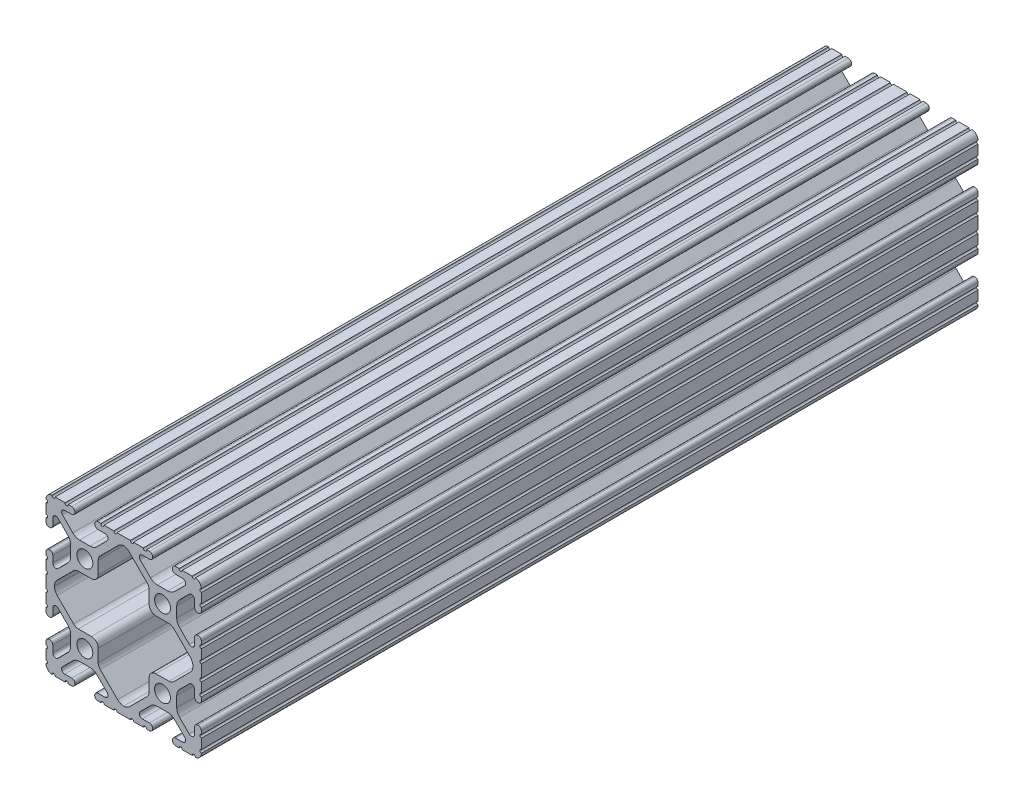
from build123d import *

# Parameters (mm, degrees)
SKETCH1_R      = 2.6035
EXTRUDE1_DEPTH = 254


with BuildPart() as part:
    # Sketch1 → Extrude1 (new body)
    with BuildSketch(Plane.XY):
        with BuildLine():
            Line((-2.210122516, -25.4), (2.210122516, -25.4))
            ThreePointArc((2.210122516, -25.4), (2.712319242, -24.815433371), (3.214515968, -25.4))
            Line((3.214515968, -25.4), (6.453532688, -25.4))
            ThreePointArc((6.453532688, -25.4), (6.955729414, -24.815433371), (7.45792614, -25.4))
            Line((7.45792614, -25.4), (8.405130016, -25.4))
            ThreePointArc((8.405130016, -25.4), (9.151169169, -25.100362415), (9.461500022, -24.358707602))
            Line((9.461500022, -24.358707602), (9.4615, -24.231492399))
            ThreePointArc((9.4615, -24.231492399), (9.151169155, -23.489837593), (8.405130016, -23.1902))
            Line((8.405130016, -23.1902), (6.087754002, -23.1902))
            ThreePointArc((6.087754002, -23.1902), (5.173448619, -22.579280675), (5.387974958, -21.500783941))
            Line((5.387974958, -21.500783941), (8.763022929, -18.12573597))
            ThreePointArc((8.763022929, -18.12573597), (9.793067061, -17.437482484), (11.008086959, -17.1958))
            Line((11.008086959, -17.1958), (14.391913041, -17.1958))
            ThreePointArc((14.391913041, -17.1958), (15.606932939, -17.437482484), (16.636977071, -18.12573597))
            Line((16.636977071, -18.12573597), (20.012025042, -21.500783941))
            ThreePointArc((20.012025042, -21.500783941), (20.223734168, -22.586011733), (19.297652818, -23.190092399))
            Line((19.297652818, -23.190092399), (16.9799, -23.190092399))
            ThreePointArc((16.9799, -23.190092399), (16.243518998, -23.495111397), (15.9385, -24.231492399))
            Line((15.9385, -24.231492399), (15.9385, -24.358492399))
            ThreePointArc((15.9385, -24.358492399), (16.248754204, -25.100286874), (16.994869984, -25.4))
            Line((16.994869984, -25.4), (18.134015685, -25.4))
            ThreePointArc((18.134015685, -25.4), (18.636212411, -24.815433371), (19.138409137, -25.4))
            Line((19.138409137, -25.4), (20.1295, -25.4))
            Line((20.1295, -25.4), (22.413213213, -25.4))
            ThreePointArc((22.413213213, -25.4), (22.915409939, -24.815433371), (23.417606664, -25.4))
            Line((23.417606664, -25.4), (23.450078724, -25.4))
            ThreePointArc((23.450078724, -25.4), (24.838729535, -24.730064765), (25.4, -23.294049529))
            Line((25.4, -23.294049529), (25.4, -23.268649529))
            ThreePointArc((25.4, -23.268649529), (24.892, -22.760649529), (25.4, -22.252649529))
            Line((25.4, -22.252649529), (25.4, -21.160449529))
            Line((25.4, -21.160449529), (25.4, -19.025239356))
            ThreePointArc((25.4, -19.025239356), (24.892, -18.517239356), (25.4, -18.009239356))
            Line((25.4, -18.009239356), (25.4, -16.91604181))
            ThreePointArc((25.4, -16.91604181), (25.094981002, -16.179660808), (24.3586, -15.87464181))
            Line((24.3586, -15.87464181), (24.2316, -15.87464181))
            ThreePointArc((24.2316, -15.87464181), (23.495218998, -16.179660808), (23.1902, -16.91604181))
            Line((23.1902, -16.91604181), (23.1902, -19.100988789))
            ThreePointArc((23.1902, -19.100988789), (22.563006367, -20.039650394), (21.45577951, -19.819409279))
            Line((21.45577951, -19.819409279), (18.27813597, -16.641765738))
            ThreePointArc((18.27813597, -16.641765738), (17.589882484, -15.611721606), (17.3482, -14.396701708))
            Line((17.3482, -14.396701708), (17.3482, -11.003495043))
            ThreePointArc((17.3482, -11.003495043), (17.590610762, -9.786718415), (18.280827, -8.755743204))
            Line((18.280827, -8.755743204), (21.45664064, -5.587529241))
            ThreePointArc((21.45664064, -5.587529241), (22.563568521, -5.368381274), (23.1902, -6.30680983))
            Line((23.1902, -6.30680983), (23.1902, -8.48395819))
            ThreePointArc((23.1902, -8.48395819), (23.495218998, -9.220339192), (24.2316, -9.52535819))
            Line((24.2316, -9.52535819), (24.3586, -9.52535819))
            ThreePointArc((24.3586, -9.52535819), (25.094981002, -9.220339192), (25.4, -8.48395819))
            Line((25.4, -8.48395819), (25.4, -7.327686685))
            ThreePointArc((25.4, -7.327686685), (24.892, -6.819686685), (25.4, -6.311686685))
            Line((25.4, -6.311686685), (25.4, -3.084276513))
            ThreePointArc((25.4, -3.084276513), (24.892, -2.576276513), (25.4, -2.068276513))
            Line((25.4, -2.068276513), (25.4, 2.068276513))
            ThreePointArc((25.4, 2.068276513), (24.892, 2.576276513), (25.4, 3.084276513))
            Line((25.4, 3.084276513), (25.4, 6.311686685))
            ThreePointArc((25.4, 6.311686685), (24.892, 6.819686685), (25.4, 7.327686685))
            Line((25.4, 7.327686685), (25.4, 8.48395819))
            ThreePointArc((25.4, 8.48395819), (25.094981002, 9.220339192), (24.3586, 9.52535819))
            Line((24.3586, 9.52535819), (24.2316, 9.52535819))
            ThreePointArc((24.2316, 9.52535819), (23.495218998, 9.220339192), (23.1902, 8.48395819))
            Line((23.1902, 8.48395819), (23.1902, 6.30680983))
            ThreePointArc((23.1902, 6.30680983), (22.563568521, 5.368381274), (21.45664064, 5.587529241))
            Line((21.45664064, 5.587529241), (18.280827, 8.755743204))
            ThreePointArc((18.280827, 8.755743204), (17.590610762, 9.786718415), (17.3482, 11.003495043))
            Line((17.3482, 11.003495043), (17.3482, 14.396701708))
            ThreePointArc((17.3482, 14.396701708), (17.589882484, 15.611721606), (18.27813597, 16.641765738))
            Line((18.27813597, 16.641765738), (21.45577951, 19.819409279))
            ThreePointArc((21.45577951, 19.819409279), (22.563006367, 20.039650394), (23.1902, 19.100988789))
            Line((23.1902, 19.100988789), (23.1902, 16.91604181))
            ThreePointArc((23.1902, 16.91604181), (23.495218998, 16.179660808), (24.2316, 15.87464181))
            Line((24.2316, 15.87464181), (24.3586, 15.87464181))
            ThreePointArc((24.3586, 15.87464181), (25.094981002, 16.179660808), (25.4, 16.91604181))
            Line((25.4, 16.91604181), (25.4, 18.009239356))
            ThreePointArc((25.4, 18.009239356), (24.892, 18.517239356), (25.4, 19.025239356))
            Line((25.4, 19.025239356), (25.4, 21.160449529))
            Line((25.4, 21.160449529), (25.4, 22.252649529))
            ThreePointArc((25.4, 22.252649529), (24.892, 22.760649529), (25.4, 23.268649529))
            Line((25.4, 23.268649529), (25.4, 23.294049529))
            ThreePointArc((25.4, 23.294049529), (24.838729535, 24.730064765), (23.450078724, 25.4))
            Line((23.450078724, 25.4), (23.417606664, 25.4))
            ThreePointArc((23.417606664, 25.4), (22.915409939, 24.815433371), (22.413213213, 25.4))
            Line((22.413213213, 25.4), (20.1295, 25.4))
            Line((20.1295, 25.4), (19.138409137, 25.4))
            ThreePointArc((19.138409137, 25.4), (18.636212411, 24.815433371), (18.134015685, 25.4))
            Line((18.134015685, 25.4), (16.994869984, 25.4))
            ThreePointArc((16.994869984, 25.4), (16.248754204, 25.100286874), (15.9385, 24.358492399))
            Line((15.9385, 24.358492399), (15.9385, 24.231492399))
            ThreePointArc((15.9385, 24.231492399), (16.243518998, 23.495111397), (16.9799, 23.190092399))
            Line((16.9799, 23.190092399), (19.297652818, 23.190092399))
            ThreePointArc((19.297652818, 23.190092399), (20.223734168, 22.586011733), (20.012025042, 21.500783941))
            Line((20.012025042, 21.500783941), (16.636977071, 18.12573597))
            ThreePointArc((16.636977071, 18.12573597), (15.606932939, 17.437482484), (14.391913041, 17.1958))
            Line((14.391913041, 17.1958), (11.008086959, 17.1958))
            ThreePointArc((11.008086959, 17.1958), (9.793067061, 17.437482484), (8.763022929, 18.12573597))
            Line((8.763022929, 18.12573597), (5.387974958, 21.500783941))
            ThreePointArc((5.387974958, 21.500783941), (5.173448619, 22.579280675), (6.087754002, 23.1902))
            Line((6.087754002, 23.1902), (8.405130016, 23.1902))
            ThreePointArc((8.405130016, 23.1902), (9.151169155, 23.489837593), (9.4615, 24.231492399))
            Line((9.4615, 24.231492399), (9.461500022, 24.358707602))
            ThreePointArc((9.461500022, 24.358707602), (9.151169169, 25.100362415), (8.405130016, 25.4))
            Line((8.405130016, 25.4), (7.45792614, 25.4))
            ThreePointArc((7.45792614, 25.4), (6.955729414, 24.815433371), (6.453532688, 25.4))
            Line((6.453532688, 25.4), (3.214515968, 25.4))
            ThreePointArc((3.214515968, 25.4), (2.712319242, 24.815433371), (2.210122516, 25.4))
            Line((2.210122516, 25.4), (-2.210122516, 25.4))
            ThreePointArc((-2.210122516, 25.4), (-2.712319242, 24.815433371), (-3.214515968, 25.4))
            Line((-3.214515968, 25.4), (-5.2705, 25.4))
            Line((-5.2705, 25.4), (-6.453532688, 25.4))
            ThreePointArc((-6.453532688, 25.4), (-6.955729414, 24.815433371), (-7.45792614, 25.4))
            Line((-7.45792614, 25.4), (-8.405130016, 25.4))
            ThreePointArc((-8.405130016, 25.4), (-9.151169169, 25.100362415), (-9.461500022, 24.358707602))
            Line((-9.461500022, 24.358707602), (-9.4615, 24.231492399))
            ThreePointArc((-9.4615, 24.231492399), (-9.151169155, 23.489837593), (-8.405130016, 23.1902))
            Line((-8.405130016, 23.1902), (-6.087754002, 23.1902))
            ThreePointArc((-6.087754002, 23.1902), (-5.173448619, 22.579280675), (-5.387974958, 21.500783941))
            Line((-5.387974958, 21.500783941), (-8.763022929, 18.12573597))
            ThreePointArc((-8.763022929, 18.12573597), (-9.793067061, 17.437482484), (-11.008086959, 17.1958))
            Line((-11.008086959, 17.1958), (-14.391913041, 17.1958))
            ThreePointArc((-14.391913041, 17.1958), (-15.606932939, 17.437482484), (-16.636977071, 18.12573597))
            Line((-16.636977071, 18.12573597), (-20.012025042, 21.500783941))
            ThreePointArc((-20.012025042, 21.500783941), (-20.223734168, 22.586011733), (-19.297652818, 23.190092399))
            Line((-19.297652818, 23.190092399), (-16.9799, 23.190092399))
            ThreePointArc((-16.9799, 23.190092399), (-16.243518998, 23.495111397), (-15.9385, 24.231492399))
            Line((-15.9385, 24.231492399), (-15.9385, 24.358492399))
            ThreePointArc((-15.9385, 24.358492399), (-16.248754204, 25.100286874), (-16.994869984, 25.4))
            Line((-16.994869984, 25.4), (-18.134015685, 25.4))
            ThreePointArc((-18.134015685, 25.4), (-18.636212411, 24.815433371), (-19.138409137, 25.4))
            Line((-19.138409137, 25.4), (-20.1295, 25.4))
            Line((-20.1295, 25.4), (-22.413213213, 25.4))
            ThreePointArc((-22.413213213, 25.4), (-22.915409939, 24.815433371), (-23.417606664, 25.4))
            Line((-23.417606664, 25.4), (-23.450078724, 25.4))
            ThreePointArc((-23.450078724, 25.4), (-24.838729535, 24.730064765), (-25.4, 23.294049529))
            Line((-25.4, 23.294049529), (-25.4, 23.268649529))
            ThreePointArc((-25.4, 23.268649529), (-24.892, 22.760649529), (-25.4, 22.252649529))
            Line((-25.4, 22.252649529), (-25.4, 21.160449529))
            Line((-25.4, 21.160449529), (-25.4, 19.025239356))
            ThreePointArc((-25.4, 19.025239356), (-24.892, 18.517239356), (-25.4, 18.009239356))
            Line((-25.4, 18.009239356), (-25.4, 16.91604181))
            ThreePointArc((-25.4, 16.91604181), (-25.094981002, 16.179660808), (-24.3586, 15.87464181))
            Line((-24.3586, 15.87464181), (-24.2316, 15.87464181))
            ThreePointArc((-24.2316, 15.87464181), (-23.495218998, 16.179660808), (-23.1902, 16.91604181))
            Line((-23.1902, 16.91604181), (-23.1902, 19.100988789))
            ThreePointArc((-23.1902, 19.100988789), (-22.563006367, 20.039650394), (-21.45577951, 19.819409279))
            Line((-21.45577951, 19.819409279), (-18.27813597, 16.641765738))
            ThreePointArc((-18.27813597, 16.641765738), (-17.589882484, 15.611721606), (-17.3482, 14.396701708))
            Line((-17.3482, 14.396701708), (-17.3482, 11.003495043))
            ThreePointArc((-17.3482, 11.003495043), (-17.590610762, 9.786718415), (-18.280827, 8.755743204))
            Line((-18.280827, 8.755743204), (-21.45664064, 5.587529241))
            ThreePointArc((-21.45664064, 5.587529241), (-22.563568521, 5.368381274), (-23.1902, 6.30680983))
            Line((-23.1902, 6.30680983), (-23.1902, 8.48395819))
            ThreePointArc((-23.1902, 8.48395819), (-23.495218998, 9.220339192), (-24.2316, 9.52535819))
            Line((-24.2316, 9.52535819), (-24.3586, 9.52535819))
            ThreePointArc((-24.3586, 9.52535819), (-25.094981002, 9.220339192), (-25.4, 8.48395819))
            Line((-25.4, 8.48395819), (-25.4, 7.327686685))
            ThreePointArc((-25.4, 7.327686685), (-24.892, 6.819686685), (-25.4, 6.311686685))
            Line((-25.4, 6.311686685), (-25.4, 3.084276513))
            ThreePointArc((-25.4, 3.084276513), (-24.892, 2.576276513), (-25.4, 2.068276513))
            Line((-25.4, 2.068276513), (-25.4, -2.068276513))
            ThreePointArc((-25.4, -2.068276513), (-24.892, -2.576276513), (-25.4, -3.084276513))
            Line((-25.4, -3.084276513), (-25.4, -4.176476513))
            Line((-25.4, -4.176476513), (-25.4, -6.311686685))
            ThreePointArc((-25.4, -6.311686685), (-24.892, -6.819686685), (-25.4, -7.327686685))
            Line((-25.4, -7.327686685), (-25.4, -8.48395819))
            ThreePointArc((-25.4, -8.48395819), (-25.094981002, -9.220339192), (-24.3586, -9.52535819))
            Line((-24.3586, -9.52535819), (-24.2316, -9.52535819))
            ThreePointArc((-24.2316, -9.52535819), (-23.495218998, -9.220339192), (-23.1902, -8.48395819))
            Line((-23.1902, -8.48395819), (-23.1902, -6.30680983))
            ThreePointArc((-23.1902, -6.30680983), (-22.563568521, -5.368381274), (-21.45664064, -5.587529241))
            Line((-21.45664064, -5.587529241), (-18.280827, -8.755743204))
            ThreePointArc((-18.280827, -8.755743204), (-17.590610762, -9.786718415), (-17.3482, -11.003495043))
            Line((-17.3482, -11.003495043), (-17.3482, -14.396701708))
            ThreePointArc((-17.3482, -14.396701708), (-17.589882484, -15.611721606), (-18.27813597, -16.641765738))
            Line((-18.27813597, -16.641765738), (-21.45577951, -19.819409279))
            ThreePointArc((-21.45577951, -19.819409279), (-22.563006367, -20.039650394), (-23.1902, -19.100988789))
            Line((-23.1902, -19.100988789), (-23.1902, -16.91604181))
            ThreePointArc((-23.1902, -16.91604181), (-23.495218998, -16.179660808), (-24.2316, -15.87464181))
            Line((-24.2316, -15.87464181), (-24.3586, -15.87464181))
            ThreePointArc((-24.3586, -15.87464181), (-25.094981002, -16.179660808), (-25.4, -16.91604181))
            Line((-25.4, -16.91604181), (-25.4, -18.009239356))
            ThreePointArc((-25.4, -18.009239356), (-24.892, -18.517239356), (-25.4, -19.025239356))
            Line((-25.4, -19.025239356), (-25.4, -21.160449529))
            Line((-25.4, -21.160449529), (-25.4, -22.252649529))
            ThreePointArc((-25.4, -22.252649529), (-24.892, -22.760649529), (-25.4, -23.268649529))
            Line((-25.4, -23.268649529), (-25.4, -23.294049529))
            ThreePointArc((-25.4, -23.294049529), (-24.838729535, -24.730064765), (-23.450078724, -25.4))
            Line((-23.450078724, -25.4), (-23.417606664, -25.4))
            ThreePointArc((-23.417606664, -25.4), (-22.915409939, -24.815433371), (-22.413213213, -25.4))
            Line((-22.413213213, -25.4), (-20.1295, -25.4))
            Line((-20.1295, -25.4), (-19.138409137, -25.4))
            ThreePointArc((-19.138409137, -25.4), (-18.636212411, -24.815433371), (-18.134015685, -25.4))
            Line((-18.134015685, -25.4), (-16.994869984, -25.4))
            ThreePointArc((-16.994869984, -25.4), (-16.248754204, -25.100286874), (-15.9385, -24.358492399))
            Line((-15.9385, -24.358492399), (-15.9385, -24.231492399))
            ThreePointArc((-15.9385, -24.231492399), (-16.243518998, -23.495111397), (-16.9799, -23.190092399))
            Line((-16.9799, -23.190092399), (-19.297652818, -23.190092399))
            ThreePointArc((-19.297652818, -23.190092399), (-20.223734168, -22.586011733), (-20.012025042, -21.500783941))
            Line((-20.012025042, -21.500783941), (-16.636977071, -18.12573597))
            ThreePointArc((-16.636977071, -18.12573597), (-15.606932939, -17.437482484), (-14.391913041, -17.1958))
            Line((-14.391913041, -17.1958), (-11.008086959, -17.1958))
            ThreePointArc((-11.008086959, -17.1958), (-9.793067061, -17.437482484), (-8.763022929, -18.12573597))
            Line((-8.763022929, -18.12573597), (-5.387974958, -21.500783941))
            ThreePointArc((-5.387974958, -21.500783941), (-5.173448619, -22.579280675), (-6.087754002, -23.1902))
            Line((-6.087754002, -23.1902), (-8.405130016, -23.1902))
            ThreePointArc((-8.405130016, -23.1902), (-9.151169155, -23.489837593), (-9.4615, -24.231492399))
            Line((-9.4615, -24.231492399), (-9.461500022, -24.358707602))
            ThreePointArc((-9.461500022, -24.358707602), (-9.151169169, -25.100362415), (-8.405130016, -25.4))
            Line((-8.405130016, -25.4), (-7.45792614, -25.4))
            ThreePointArc((-7.45792614, -25.4), (-6.955729414, -24.815433371), (-6.453532688, -25.4))
            Line((-6.453532688, -25.4), (-5.2705, -25.4))
            Line((-5.2705, -25.4), (-3.214515968, -25.4))
            ThreePointArc((-3.214515968, -25.4), (-2.712319242, -24.815433371), (-2.210122516, -25.4))
        make_face()
        with Locations((12.7, -12.7)):
            Circle(SKETCH1_R, mode=Mode.SUBTRACT)
        with Locations((-12.7, -12.7)):
            Circle(SKETCH1_R, mode=Mode.SUBTRACT)
        with Locations((-12.7, 12.7)):
            Circle(SKETCH1_R, mode=Mode.SUBTRACT)
        with Locations((12.7, 12.7)):
            Circle(SKETCH1_R, mode=Mode.SUBTRACT)
        with BuildLine():
            Line((-1.987770861, -21.775858908), (-7.683964565, -16.079665203))
            ThreePointArc((-7.683964565, -16.079665203), (-8.162988991, -15.362754487), (-8.3312, -14.517100638))
            Line((-8.3312, -14.517100638), (-8.3312, -10.3886))
            ThreePointArc((-8.3312, -10.3886), (-8.978435435, -8.826035435), (-10.541, -8.1788))
            Line((-10.541, -8.1788), (-14.816495758, -8.1788))
            ThreePointArc((-14.816495758, -8.1788), (-15.66092662, -8.01109514), (-16.377187366, -7.53343528))
            Line((-16.377187366, -7.53343528), (-21.77338316, -2.150152507))
            ThreePointArc((-21.77338316, -2.150152507), (-22.408382099, -1.201655313), (-22.6314, -0.082220815))
            Line((-22.6314, -0.082220815), (-22.6314, 0.082220815))
            ThreePointArc((-22.6314, 0.082220815), (-22.408382099, 1.201655313), (-21.77338316, 2.150152507))
            Line((-21.77338316, 2.150152507), (-16.377187366, 7.53343528))
            ThreePointArc((-16.377187366, 7.53343528), (-15.66092662, 8.01109514), (-14.816495758, 8.1788))
            Line((-14.816495758, 8.1788), (-10.541, 8.1788))
            ThreePointArc((-10.541, 8.1788), (-8.978435435, 8.826035435), (-8.3312, 10.3886))
            Line((-8.3312, 10.3886), (-8.3312, 14.517100638))
            ThreePointArc((-8.3312, 14.517100638), (-8.162988991, 15.362754487), (-7.683964565, 16.079665203))
            Line((-7.683964565, 16.079665203), (-1.795557487, 21.968072281))
            ThreePointArc((-1.795557487, 21.968072281), (-0.97153248, 22.546678968), (0, 22.811117151))
            ThreePointArc((0, 22.811117151), (0.97153248, 22.546678968), (1.795557487, 21.968072281))
            Line((1.795557487, 21.968072281), (7.683964565, 16.079665203))
            ThreePointArc((7.683964565, 16.079665203), (8.162988991, 15.362754487), (8.3312, 14.517100638))
            Line((8.3312, 14.517100638), (8.3312, 12.700098375))
            Line((8.3312, 12.700098375), (8.3312, 10.389032234))
            ThreePointArc((8.3312, 10.389032234), (8.978435435, 8.826467669), (10.541, 8.179232234))
            Line((10.541, 8.179232234), (14.816062488, 8.179232234))
            ThreePointArc((14.816062488, 8.179232234), (15.660493349, 8.011527374), (16.376754096, 7.533867514))
            Line((16.376754096, 7.533867514), (21.77338316, 2.150152507))
            ThreePointArc((21.77338316, 2.150152507), (22.408382099, 1.201655313), (22.6314, 0.082220815))
            Line((22.6314, 0.082220815), (22.6314, -0.082220815))
            ThreePointArc((22.6314, -0.082220815), (22.408382099, -1.201655313), (21.77338316, -2.150152507))
            Line((21.77338316, -2.150152507), (16.377187366, -7.53343528))
            ThreePointArc((16.377187366, -7.53343528), (15.66092662, -8.01109514), (14.816495758, -8.1788))
            Line((14.816495758, -8.1788), (10.541, -8.1788))
            ThreePointArc((10.541, -8.1788), (8.978435435, -8.826035435), (8.3312, -10.3886))
            Line((8.3312, -10.3886), (8.3312, -14.517100638))
            ThreePointArc((8.3312, -14.517100638), (8.162988991, -15.362754487), (7.683964565, -16.079665203))
            Line((7.683964565, -16.079665203), (1.987770861, -21.775858908))
            ThreePointArc((1.987770861, -21.775858908), (1.075921771, -22.393947165), (0, -22.630366707))
            ThreePointArc((0, -22.630366707), (-1.075921771, -22.393947165), (-1.987770861, -21.775858908))
        make_face(mode=Mode.SUBTRACT)
    extrude(amount=-EXTRUDE1_DEPTH)


solid = part.part
